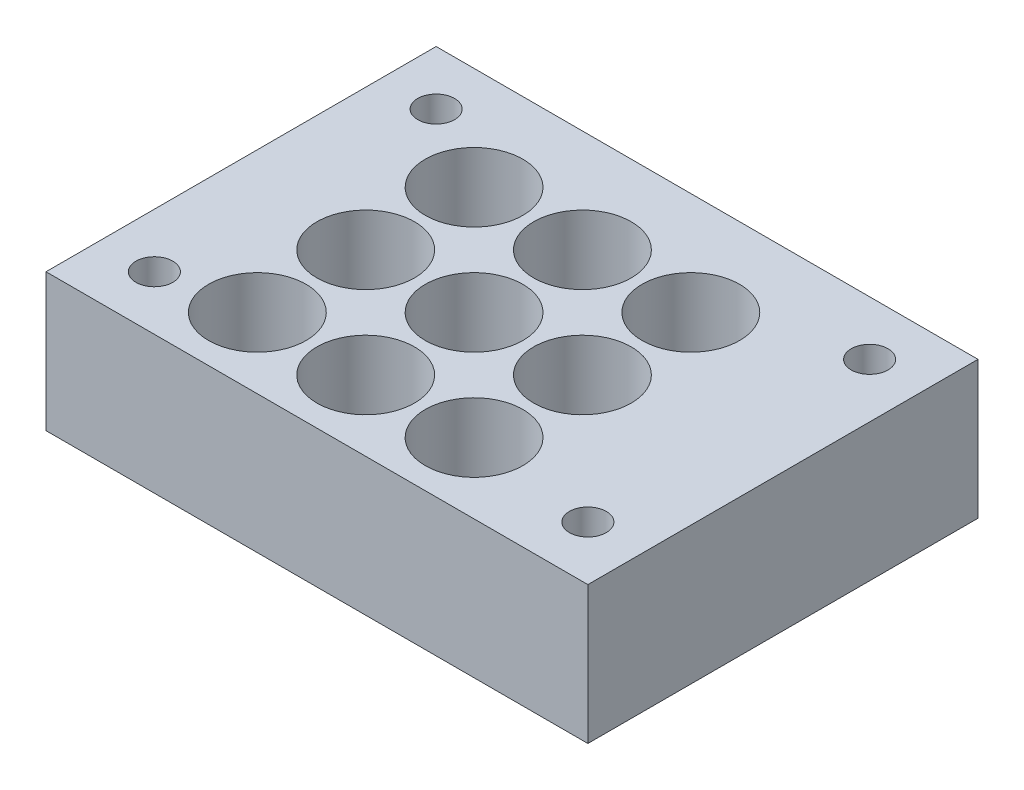
from build123d import *

# Parameters (mm, degrees)
SKETCH1_W           = 50
SKETCH1_H           = 36
SKETCH1_R           = 4.5
SKETCH1_R_2         = 1.7
BOSS_EXTRUDE1_DEPTH = 12.7


with BuildPart() as part:
    # Sketch1 → Boss-Extrude1 (new body)
    with BuildSketch(Plane(origin=(0, 0, 0), x_dir=(1, 0, 0), z_dir=(0, 1, 0))):
        with Locations((25, 18)):
            Rectangle(SKETCH1_W, SKETCH1_H)
        with Locations((13, 6.5)):
            Circle(SKETCH1_R, mode=Mode.SUBTRACT)
        with Locations((5, 5)):
            Circle(SKETCH1_R_2, mode=Mode.SUBTRACT)
        with Locations((5, 31)):
            Circle(SKETCH1_R_2, mode=Mode.SUBTRACT)
        with Locations((45, 31)):
            Circle(SKETCH1_R_2, mode=Mode.SUBTRACT)
        with Locations((45, 5)):
            Circle(SKETCH1_R_2, mode=Mode.SUBTRACT)
        with Locations((23, 6.5)):
            Circle(SKETCH1_R, mode=Mode.SUBTRACT)
        with Locations((33, 6.5)):
            Circle(SKETCH1_R, mode=Mode.SUBTRACT)
        with Locations((23, 16.5)):
            Circle(SKETCH1_R, mode=Mode.SUBTRACT)
        with Locations((33, 16.5)):
            Circle(SKETCH1_R, mode=Mode.SUBTRACT)
        with Locations((23, 26.5)):
            Circle(SKETCH1_R, mode=Mode.SUBTRACT)
        with Locations((33, 26.5)):
            Circle(SKETCH1_R, mode=Mode.SUBTRACT)
        with Locations((13, 16.5)):
            Circle(SKETCH1_R, mode=Mode.SUBTRACT)
        with Locations((13, 26.5)):
            Circle(SKETCH1_R, mode=Mode.SUBTRACT)
    extrude(amount=BOSS_EXTRUDE1_DEPTH)


solid = part.part
